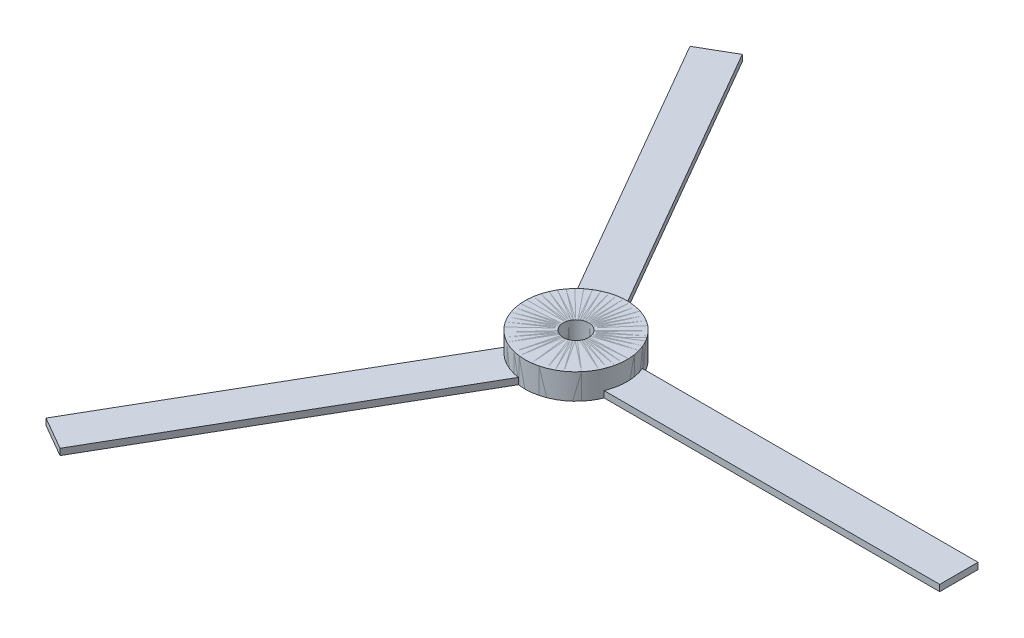
from build123d import *

# Parameters (mm, degrees)
SKETCH1_R           = 4
SKETCH1_R_2         = 1
BOSS_EXTRUDE1_DEPTH = 2
CIRPATTERN2_COUNT   = 3
BOSS_EXTRUDE5_START = -2
SKETCH5_W           = 30
SKETCH5_H           = 3
BOSS_EXTRUDE5_DEPTH = 0.5
CIRPATTERN4_COUNT   = 3
SKETCH6_R           = 1
CUT_EXTRUDE1_DEPTH  = 10


with BuildPart() as part:
    # Sketch1 → Boss-Extrude1 (new body)
    with BuildSketch(Plane(origin=(0, 0, 0), x_dir=(1, 0, 0), z_dir=(0, 1, 0))):
        Circle(SKETCH1_R)
        Circle(SKETCH1_R_2, mode=Mode.SUBTRACT)
    extrude(amount=BOSS_EXTRUDE1_DEPTH)


with BuildPart() as cirpattern2_1:
    # CirPattern2: pattern copy
    add(part.part.rotate(Axis((0, 2, 0), (0, 1, 0)), 1 * 360 / CIRPATTERN2_COUNT))


with BuildPart() as cirpattern2_2:
    # CirPattern2: pattern copy
    add(part.part.rotate(Axis((0, 2, 0), (0, 1, 0)), 2 * 360 / CIRPATTERN2_COUNT))


with BuildPart() as body_4:
    # Sketch5 → Boss-Extrude5 (new body)
    with BuildSketch(Plane(origin=(0, 2, 0), x_dir=(1, 0, 0), z_dir=(0, 1, 0)).offset(BOSS_EXTRUDE5_START)):
        with Locations((15, 0)):
            Rectangle(SKETCH5_W, SKETCH5_H)
    extrude(amount=BOSS_EXTRUDE5_DEPTH)


with BuildPart() as cirpattern4_1:
    # CirPattern4: pattern copy
    add(body_4.part.rotate(Axis((0, 0, 0), (0, 1, 0)), 1 * 360 / CIRPATTERN4_COUNT))


with BuildPart() as cirpattern4_2:
    # CirPattern4: pattern copy
    add(body_4.part.rotate(Axis((0, 0, 0), (0, 1, 0)), 2 * 360 / CIRPATTERN4_COUNT))


with BuildPart() as cut_extrude1_tool:
    # Sketch6 → Cut-Extrude1 (new body)
    with BuildSketch(Plane(origin=(0, 2, 0), x_dir=(1, 0, 0), z_dir=(0, 1, 0))):
        Circle(SKETCH6_R)
    extrude(amount=-CUT_EXTRUDE1_DEPTH)


with BuildPart() as body_4_1:
    add(body_4.part)

    # Cut-Extrude1: cut by cut_extrude1_tool
    add(cut_extrude1_tool.part, mode=Mode.SUBTRACT)


with BuildPart() as cirpattern4_1_1:
    add(cirpattern4_1.part)

    # Cut-Extrude1: cut by cut_extrude1_tool
    add(cut_extrude1_tool.part, mode=Mode.SUBTRACT)


with BuildPart() as cirpattern4_2_1:
    add(cirpattern4_2.part)

    # Cut-Extrude1: cut by cut_extrude1_tool
    add(cut_extrude1_tool.part, mode=Mode.SUBTRACT)


solid = Compound([part.part, cirpattern2_1.part, cirpattern2_2.part, body_4_1.part, cirpattern4_1_1.part, cirpattern4_2_1.part])
